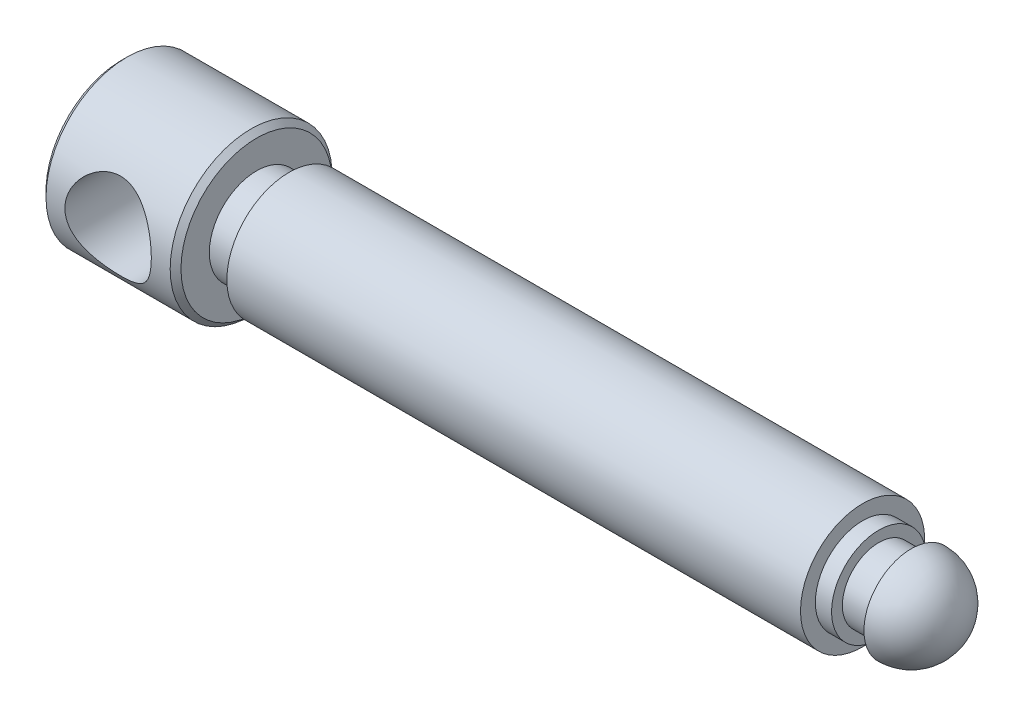
from build123d import *

# Parameters (mm, degrees)
CHAMFER1_SIZE      = 2
SKETCH5_R          = 16
CUT_EXTRUDE2_DEPTH = 61


with BuildPart() as part:
    # Sketch1 → Revolve1 (revolve)
    with BuildSketch(Plane.XY):
        with BuildLine():
            Line((-263.540634281, 0), (-263.540634281, 30))
            Line((-263.540634281, 30), (-213.540634281, 30))
            Line((-213.540634281, 30), (-213.540634281, 17.5))
            Line((-213.540634281, 17.5), (-201.540634281, 17.5))
            Line((-201.540634281, 17.5), (-201.540634281, 23))
            Line((-201.540634281, 23), (10.959365719, 23))
            Line((10.959365719, 23), (10.959365719, 17.5))
            Line((10.959365719, 17.5), (16.959365719, 17.5))
            Line((16.959365719, 17.5), (16.959365719, 13.5))
            Line((16.959365719, 13.5), (28.959365719, 13.5))
            Line((28.959365719, 13.5), (28.959365719, 17.5))
            ThreePointArc((28.959365719, 17.5), (41.333734389, 12.374368671), (46.459365719, 0))
            Line((46.459365719, 0), (-263.540634281, 0))
        make_face()
    revolve(axis=Axis((-145.227257267, 0, 0), (1, 0, 0)))

    # Chamfer1
    chamfer1_edges = [part.edges().sort_by_distance(p)[0] for p in [
        (-213.540634281, -30, 0),
        (-263.540634281, -30, 0),
    ]]
    chamfer(chamfer1_edges, length=CHAMFER1_SIZE)

    # Sketch5 → Cut-Extrude2 (cut, through all)
    with BuildSketch(Plane.XY.offset(30)):
        with Locations((-238.540634281, 0)):
            Circle(SKETCH5_R)
    extrude(amount=-CUT_EXTRUDE2_DEPTH, mode=Mode.SUBTRACT)


solid = part.part
